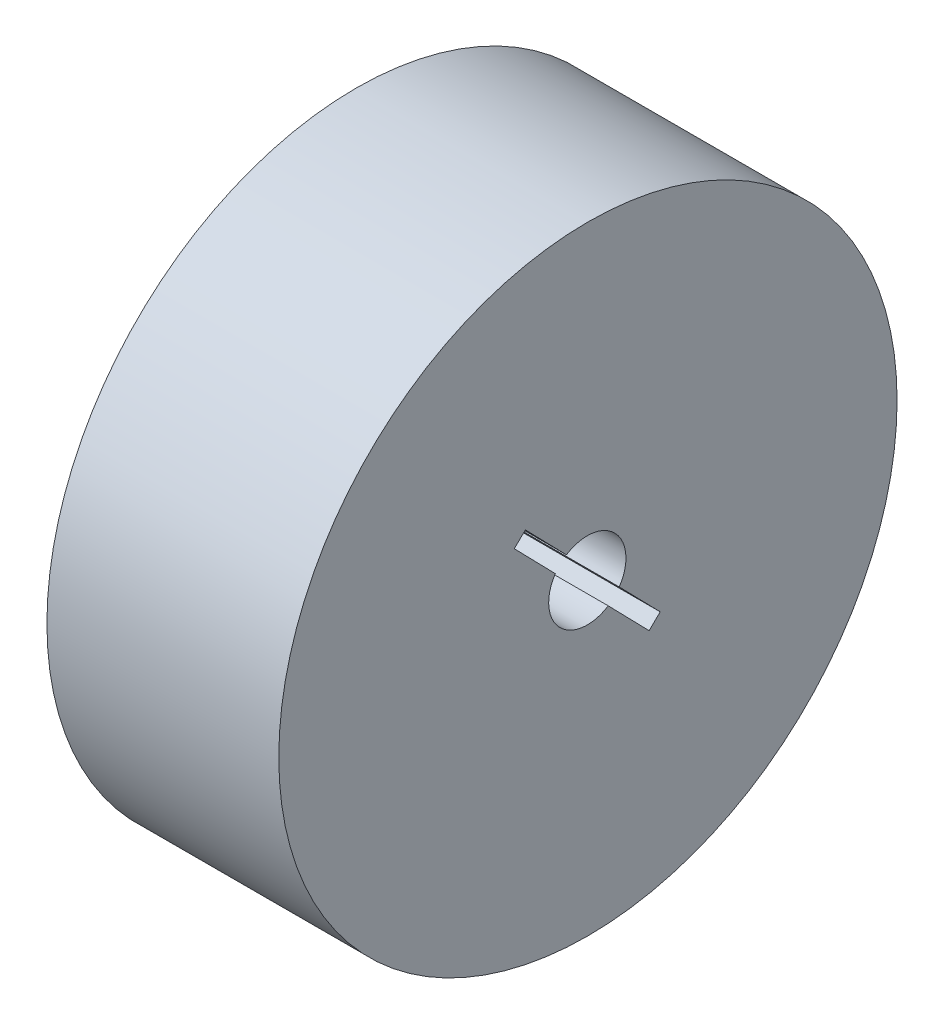
from build123d import *

# Parameters (mm, degrees)
SKETCH_1_R          = 40
EXTRUDE_1_DEPTH     = 30
CUT_EXTRUDE_1_DEPTH = 31


with BuildPart() as part:
    # 草图1 → 凸台-拉伸1 (new body)
    with BuildSketch(Plane(origin=(0, 0, 0), x_dir=(0, 0, -1), z_dir=(1, 0, 0))):
        Circle(SKETCH_1_R)
    extrude(amount=EXTRUDE_1_DEPTH)

    # 草图2 → 切除-拉伸1 (cut, through all)
    with BuildSketch(Plane(origin=(0, 0, 0), x_dir=(0, 0, -1), z_dir=(1, 0, 0))):
        with BuildLine():
            Line((2.623542319, -4.321331792), (7.918602352, -9.756071778))
            Line((7.918602352, -9.756071778), (9.351104694, -8.360386627))
            Line((9.351104694, -8.360386627), (4.055722569, -2.925316052))
            ThreePointArc((4.055722569, -2.925316052), (3.501362158, 3.37399969), (-2.781388072, 4.092152751))
            Line((-2.781388072, 4.092152751), (-8.094959692, 9.545892647))
            Line((-8.094959692, 9.545892647), (-9.527462034, 8.150207496))
            Line((-9.527462034, 8.150207496), (-4.214212506, 2.696798189))
            ThreePointArc((-4.214212506, 2.696798189), (-3.661149551, -3.604426065), (2.623542319, -4.321331792))
        make_face()
    extrude(amount=CUT_EXTRUDE_1_DEPTH, mode=Mode.SUBTRACT)


solid = part.part
